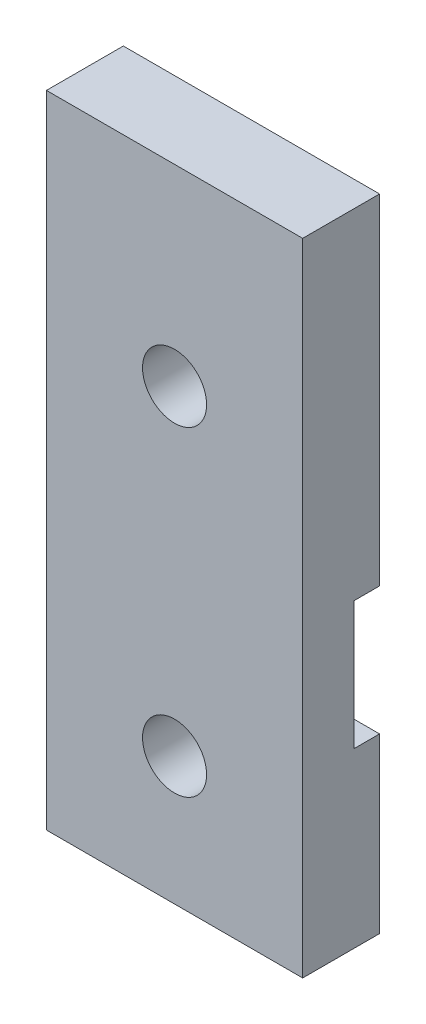
from build123d import *

# Parameters (mm, degrees)
ESBO_O1_W                = 20
ESBO_O1_H                = 50
RESSALTO_EXTRUS_O1_DEPTH = 6
ESBO_O2_R                = 2.5
CORTE_EXTRUS_O1_DEPTH    = 10
ESBO_O3_R                = 5
CORTE_EXTRUS_O2_DEPTH    = 2
ESBO_O4_W                = 3.25
ESBO_O4_H                = 10
CORTE_EXTRUS_O3_DEPTH    = 2
ESBO_O5_R                = 2.5
RESSALTO_EXTRUS_O2_DEPTH = 4


with BuildPart() as part:
    # Esboço1 → Ressalto-extrusão1 (new body)
    with BuildSketch(Plane.XY):
        with Locations((10, 25)):
            Rectangle(ESBO_O1_W, ESBO_O1_H)
    extrude(amount=RESSALTO_EXTRUS_O1_DEPTH)

    # Esboço2 → Corte-extrusão1 (cut)
    with BuildSketch(Plane(origin=(0, 0, 0), x_dir=(-1, 0, 0), z_dir=(0, 0, -1))):
        with Locations((-10, 35)):
            Circle(ESBO_O2_R)
        with Locations((-3.25, 18.5)):
            Circle(ESBO_O2_R)
        with Locations((-10, 10)):
            Circle(ESBO_O2_R)
    extrude(amount=-CORTE_EXTRUS_O1_DEPTH, mode=Mode.SUBTRACT)

    # Esboço3 → Corte-extrusão2 (cut)
    with BuildSketch(Plane.XY):
        with Locations((3.25, 18.5)):
            Circle(ESBO_O3_R)
        with Locations((16.75, 18.5)):
            Circle(ESBO_O3_R)
    extrude(amount=CORTE_EXTRUS_O2_DEPTH, mode=Mode.SUBTRACT)

    # Esboço4 → Corte-extrusão3 (cut)
    with BuildSketch(Plane(origin=(0, 0, 0), x_dir=(-1, 0, 0), z_dir=(0, 0, -1))):
        with Locations((-1.625, 18.5)):
            Rectangle(ESBO_O4_W, ESBO_O4_H)
        with Locations((-18.375, 18.5)):
            Rectangle(ESBO_O4_W, ESBO_O4_H)
    extrude(amount=-CORTE_EXTRUS_O3_DEPTH, mode=Mode.SUBTRACT)

    # Esboço5 → Ressalto-extrusão2 (add)
    with BuildSketch(Plane.XY.offset(6)):
        with Locations((3.25, 18.5)):
            Circle(ESBO_O5_R)
    extrude(amount=-RESSALTO_EXTRUS_O2_DEPTH)


solid = part.part
